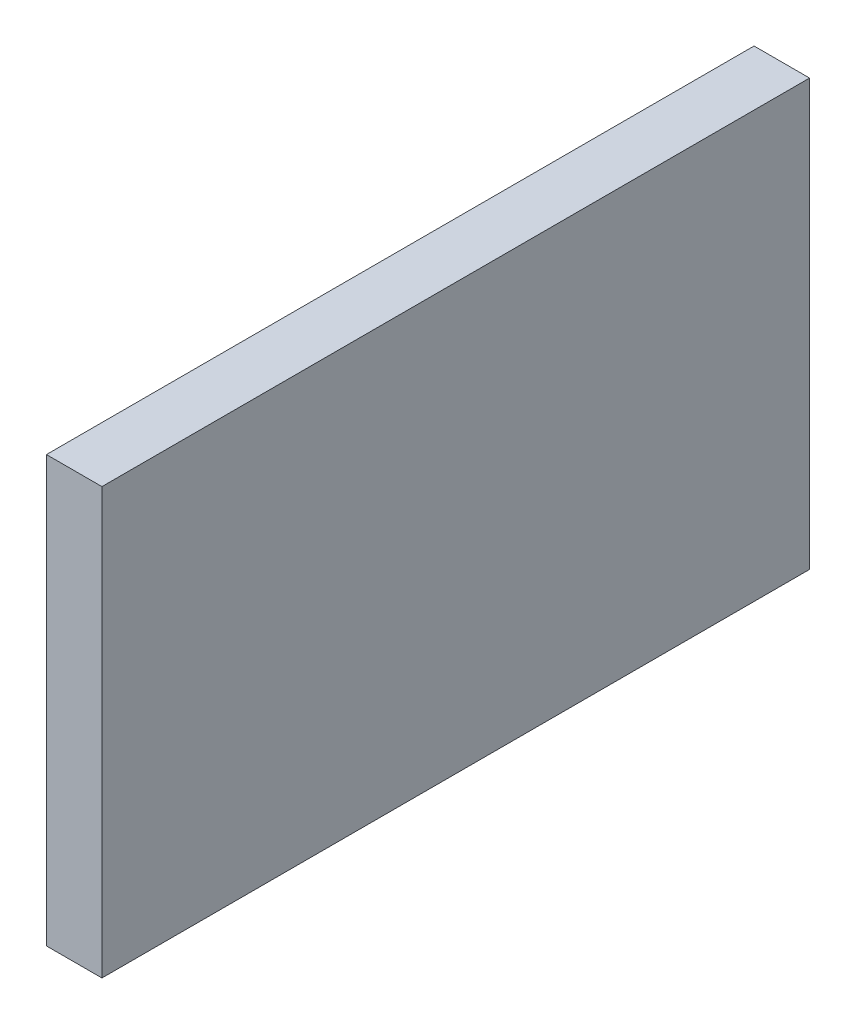
from build123d import *

# Parameters (mm, degrees)
SKETCH1_W           = 3
SKETCH1_H           = 23.003536126
BOSS_EXTRUDE1_DEPTH = 38.25


with BuildPart() as part:
    # Sketch1 → Boss-Extrude1 (new body)
    with BuildSketch(Plane(origin=(0, 0, 76.030531955), x_dir=(-1, 0, 0), z_dir=(0, 0, -1))):
        with Locations((-54.857732215, 33.325057501)):
            Rectangle(SKETCH1_W, SKETCH1_H)
    extrude(amount=BOSS_EXTRUDE1_DEPTH)


solid = part.part
